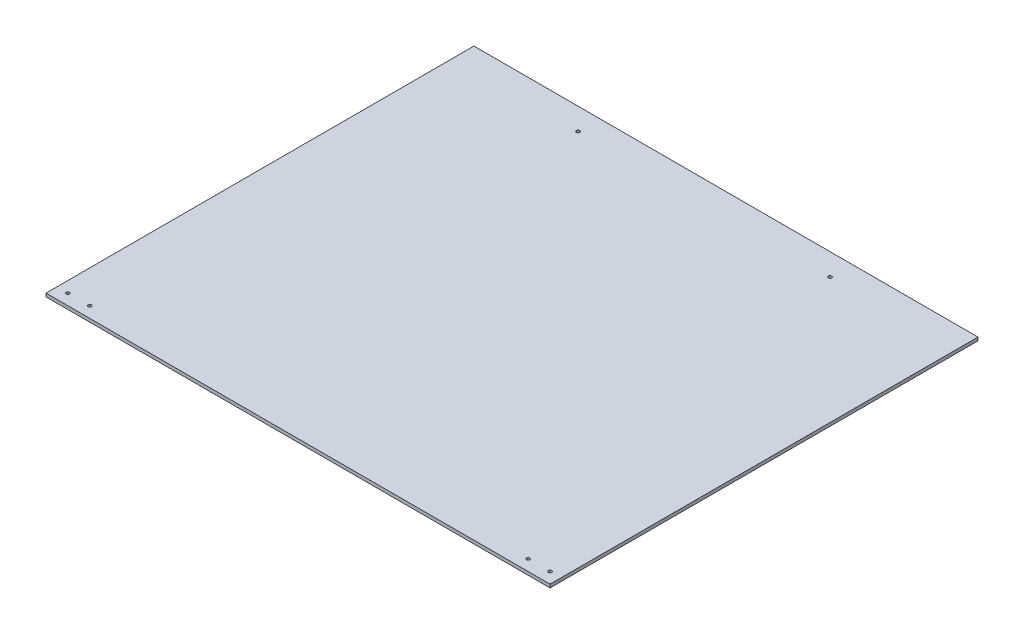
from build123d import *

# Parameters (mm, degrees)
SKETCH3_R           = 1.5
BOSS_EXTRUDE2_DEPTH = 3
SKETCH4_R           = 1.5
CUT_EXTRUDE1_DEPTH  = 3


with BuildPart() as part:
    # Sketch3 → Boss-Extrude2 (new body)
    with BuildSketch(Plane(origin=(0, 0, 0), x_dir=(1, 0, 0), z_dir=(0, 1, 0))):
        Polygon((-190.289572375, 141.737381871), (-295.289572375, 141.737381871), (-295.289572375, -248.794136117), (164.709727779, -248.794136117), (164.709727779, 141.737381871), (59.710427625, 141.737381871), (39.710427625, 141.737381871), (-170.289572375, 141.737381871), align=None)
        with Locations((-180.289572375, 121.737381871)):
            Circle(SKETCH3_R, mode=Mode.SUBTRACT)
        with Locations((49.710427625, 121.737381871)):
            Circle(SKETCH3_R, mode=Mode.SUBTRACT)
    extrude(amount=BOSS_EXTRUDE2_DEPTH)

    # Sketch4 → Cut-Extrude1 (cut)
    with BuildSketch(Plane(origin=(0, 3, 0), x_dir=(1, 0, 0), z_dir=(0, 1, 0))):
        with Locations((134.709727779, -238.794136117)):
            Circle(SKETCH4_R)
        with Locations((154.709727779, -238.794136117)):
            Circle(SKETCH4_R)
        with Locations((-285.289572375, -238.794136117)):
            Circle(SKETCH4_R)
        with Locations((-265.289572375, -238.794136117)):
            Circle(SKETCH4_R)
    extrude(amount=-CUT_EXTRUDE1_DEPTH, mode=Mode.SUBTRACT)


solid = part.part
